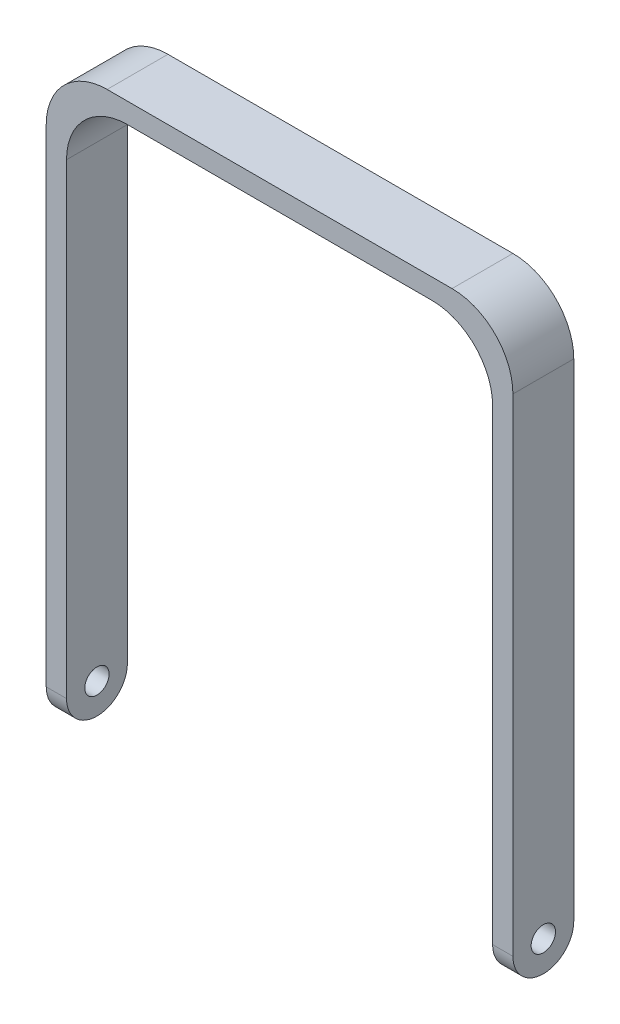
from build123d import *

# Parameters (mm, degrees)
BOSS_EXTRUDE1_DEPTH     = 4.7625
SKETCH2_R               = 1.905
CUT_EXTRUDE1_DEPTH      = 1
CUT_EXTRUDE1_DEPTH_BACK = 74.025
FILLET1_R               = 9.525


with BuildPart() as part:
    # Sketch1 → Boss-Extrude1 (new body, symmetric)
    with BuildSketch(Plane.XY):
        Polygon((33.3375, -46.0375), (36.5125, -46.0375), (36.5125, 46.0375), (-36.5125, 46.0375), (-36.5125, -46.0375), (-33.3375, -46.0375), (-33.3375, 42.8625), (33.3375, 42.8625), align=None)
    extrude(amount=BOSS_EXTRUDE1_DEPTH, both=True)

    # Sketch2 → Cut-Extrude1 (cut, two sides)
    with BuildSketch(Plane.ZY.offset(36.5125)) as cut_extrude1_sk:
        with Locations((0, -39.6875)):
            Circle(SKETCH2_R)
        with BuildLine():
            Line((-4.7625, -39.6875), (-4.7625, -46.0375))
            Line((-4.7625, -46.0375), (4.7625, -46.0375))
            Line((4.7625, -46.0375), (4.7625, -39.6875))
            ThreePointArc((4.7625, -39.6875), (0, -44.45), (-4.7625, -39.6875))
        make_face()
    extrude(amount=CUT_EXTRUDE1_DEPTH, mode=Mode.SUBTRACT)
    extrude(cut_extrude1_sk.sketch, amount=-CUT_EXTRUDE1_DEPTH_BACK, mode=Mode.SUBTRACT)

    # Fillet1
    fillet1_edges = [part.edges().sort_by_distance(p)[0] for p in [
        (33.3375, 42.8625, 0),
        (-33.3375, 42.8625, 0),
        (-36.5125, 46.0375, 0),
        (36.5125, 46.0375, 0),
    ]]
    fillet(fillet1_edges, radius=FILLET1_R)


solid = part.part
